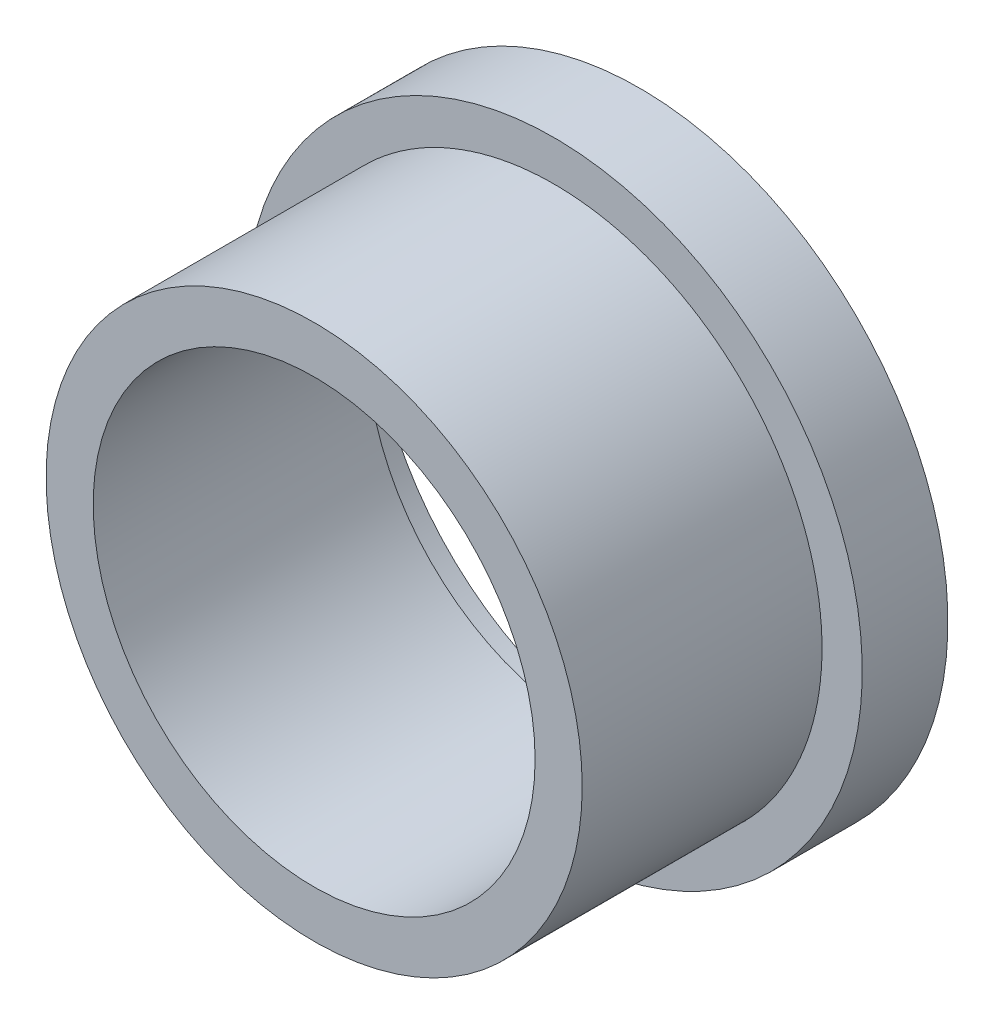
from build123d import *

# Parameters (mm, degrees)
SKETCH1_R                = 7.825
SKETCH1_R_2              = 6.45
BOSS_EXTRUDE1_DEPTH      = 8
SKETCH2_R                = 9
SKETCH2_R_2              = 7.825
BOSS_EXTRUDE2_DEPTH      = 1.5
BOSS_EXTRUDE2_DEPTH_BACK = 1


with BuildPart() as part:
    # Sketch1 → Boss-Extrude1 (new body)
    with BuildSketch(Plane.XY):
        Circle(SKETCH1_R)
        Circle(SKETCH1_R_2, mode=Mode.SUBTRACT)
    extrude(amount=BOSS_EXTRUDE1_DEPTH)


with BuildPart() as body_2:
    # Sketch2 → Boss-Extrude2 (new body, two sides)
    with BuildSketch(Plane(origin=(0, 0, 0), x_dir=(-1, 0, 0), z_dir=(0, 0, -1))) as boss_extrude2_sk:
        Circle(SKETCH2_R)
        Circle(SKETCH2_R_2, mode=Mode.SUBTRACT)
    extrude(amount=BOSS_EXTRUDE2_DEPTH)
    extrude(boss_extrude2_sk.sketch, amount=-BOSS_EXTRUDE2_DEPTH_BACK)


solid = Compound([part.part, body_2.part])
